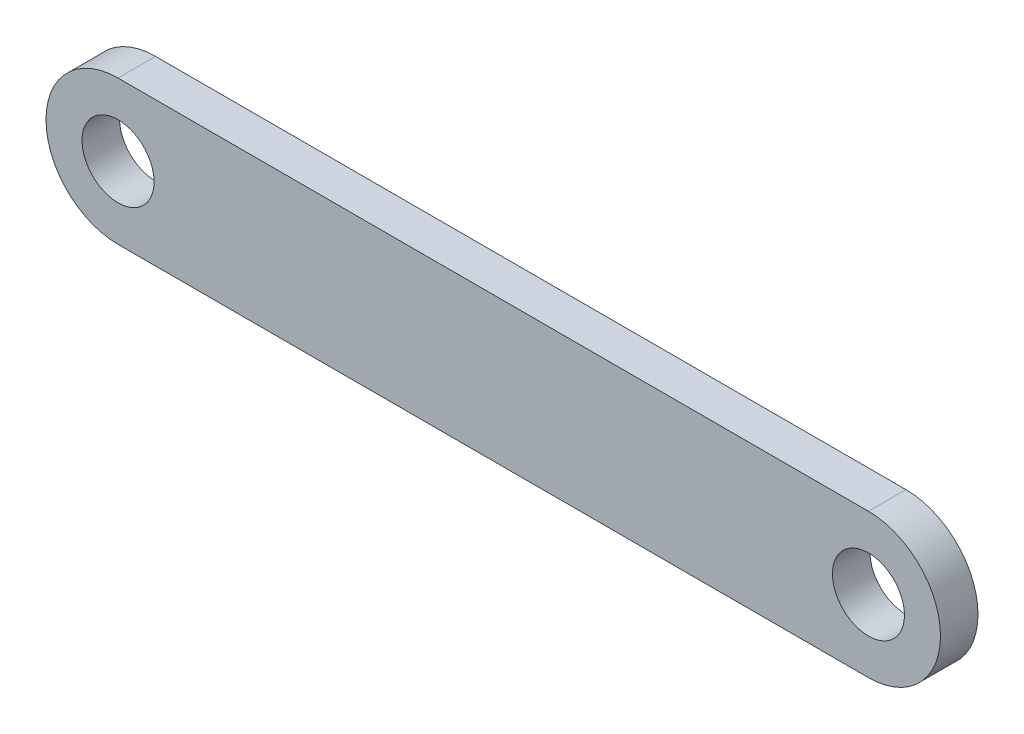
from build123d import *

# Parameters (mm, degrees)
SKETCH1_R           = 6
BOSS_EXTRUDE1_DEPTH = 3.125


with BuildPart() as part:
    # Sketch1 → Boss-Extrude1 (new body, symmetric)
    with BuildSketch(Plane.XY):
        with BuildLine():
            Line((0, 12), (125, 12))
            ThreePointArc((125, 12), (137, 0), (125, -12))
            Line((125, -12), (0, -12))
            ThreePointArc((0, -12), (-12, 0), (0, 12))
        make_face()
        Circle(SKETCH1_R, mode=Mode.SUBTRACT)
        with Locations((125, 0)):
            Circle(SKETCH1_R, mode=Mode.SUBTRACT)
    extrude(amount=BOSS_EXTRUDE1_DEPTH, both=True)


solid = part.part
